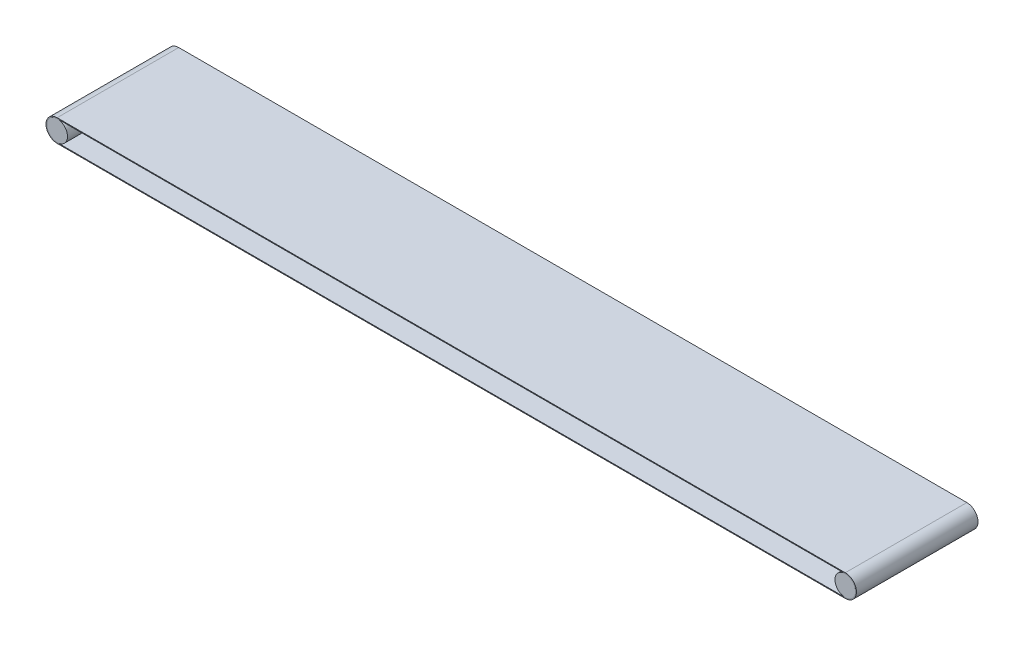
from build123d import *

# Parameters (mm, degrees)
SKETCH1_R             = 25.5
BOSS_EXTRUDE1_DEPTH   = 300
BOSS_EXTRUDE1_2_DEPTH = 300
BOSS_EXTRUDE2_DEPTH   = 300


with BuildPart() as part:
    # Sketch1 → Boss-Extrude1 (new body)
    with BuildSketch(Plane.XY):
        with Locations((-972.5, 0)):
            Circle(SKETCH1_R)
    extrude(amount=BOSS_EXTRUDE1_DEPTH)


with BuildPart() as body_2:
    # Sketch1 → Boss-Extrude1 2 (new body)
    with BuildSketch(Plane.XY):
        with Locations((972.5, 0)):
            Circle(SKETCH1_R)
    extrude(amount=BOSS_EXTRUDE1_2_DEPTH)


with BuildPart() as body_3:
    # Sketch2 → Boss-Extrude2 (new body)
    with BuildSketch(Plane.XY.offset(300)):
        with BuildLine():
            Line((-972.5, 27.5), (972.5, 27.5))
            ThreePointArc((972.5, 27.5), (1000, 0), (972.5, -27.5))
            Line((972.5, -27.5), (-972.5, -27.5))
            ThreePointArc((-972.5, -27.5), (-1000, 0), (-972.5, 27.5))
        make_face()
        with BuildLine():
            Line((-972.5, 25.5), (972.5, 25.5))
            ThreePointArc((972.5, 25.5), (998, 0), (972.5, -25.5))
            Line((972.5, -25.5), (-972.5, -25.5))
            ThreePointArc((-972.5, -25.5), (-998, 0), (-972.5, 25.5))
        make_face(mode=Mode.SUBTRACT)
    extrude(amount=-BOSS_EXTRUDE2_DEPTH)


solid = Compound([part.part, body_2.part, body_3.part])
